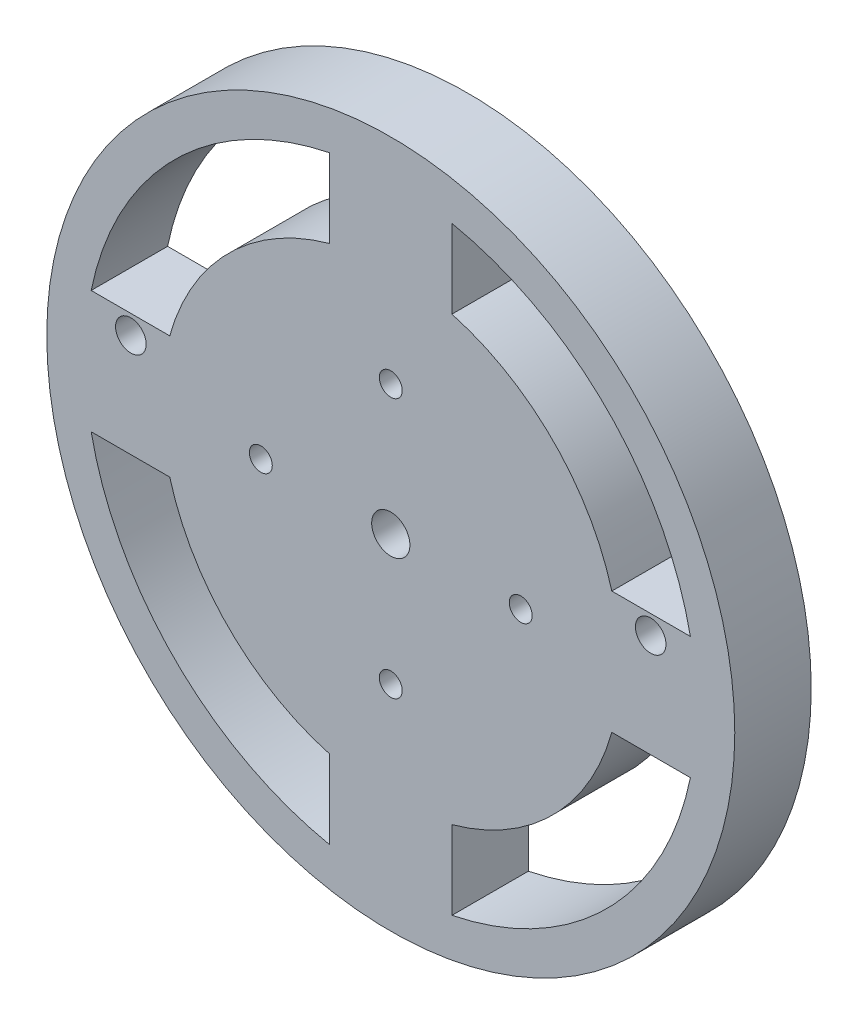
from build123d import *

# Parameters (mm, degrees)
SKETCH1_R           = 45
SKETCH1_R_2         = 2.5
SKETCH1_R_3         = 1.5
BOSS_EXTRUDE1_DEPTH = 10
SKETCH3_R           = 2
CUT_EXTRUDE1_DEPTH  = 10


with BuildPart() as part:
    # Sketch1 → Boss-Extrude1 (new body)
    with BuildSketch(Plane.XY):
        Circle(SKETCH1_R)
        Circle(SKETCH1_R_2, mode=Mode.SUBTRACT)
        with Locations((0, 17)):
            Circle(SKETCH1_R_3, mode=Mode.SUBTRACT)
        with Locations((17, 0)):
            Circle(SKETCH1_R_3, mode=Mode.SUBTRACT)
        with Locations((0, -17)):
            Circle(SKETCH1_R_3, mode=Mode.SUBTRACT)
        with Locations((-17, 0)):
            Circle(SKETCH1_R_3, mode=Mode.SUBTRACT)
        with BuildLine():
            Line((28.91366459, 8), (39.191835885, 8))
            ThreePointArc((39.191835885, 8), (28.284271247, 28.284271247), (8, 39.191835885))
            Line((8, 39.191835885), (8, 28.91366459))
            ThreePointArc((8, 28.91366459), (21.213203436, 21.213203436), (28.91366459, 8))
        make_face(mode=Mode.SUBTRACT)
        with BuildLine():
            Line((28.91366459, -8), (39.191835885, -8))
            ThreePointArc((39.191835885, -8), (28.284271247, -28.284271247), (8, -39.191835885))
            Line((8, -39.191835885), (8, -28.91366459))
            ThreePointArc((8, -28.91366459), (21.213203436, -21.213203436), (28.91366459, -8))
        make_face(mode=Mode.SUBTRACT)
        with BuildLine():
            Line((-8, -28.91366459), (-8, -39.191835885))
            ThreePointArc((-8, -39.191835885), (-28.284271247, -28.284271247), (-39.191835885, -8))
            Line((-39.191835885, -8), (-28.91366459, -8))
            ThreePointArc((-28.91366459, -8), (-21.213203436, -21.213203436), (-8, -28.91366459))
        make_face(mode=Mode.SUBTRACT)
        with BuildLine():
            Line((-39.191835885, 8), (-28.91366459, 8))
            ThreePointArc((-28.91366459, 8), (-21.213203436, 21.213203436), (-8, 28.91366459))
            Line((-8, 28.91366459), (-8, 39.191835885))
            ThreePointArc((-8, 39.191835885), (-28.284271247, 28.284271247), (-39.191835885, 8))
        make_face(mode=Mode.SUBTRACT)
    extrude(amount=BOSS_EXTRUDE1_DEPTH)

    # Sketch3 → Cut-Extrude1 (cut)
    with BuildSketch(Plane.XY.offset(10)):
        with Locations((-34, 5.5)):
            Circle(SKETCH3_R)
        with Locations((34, 5.5)):
            Circle(SKETCH3_R)
    extrude(amount=-CUT_EXTRUDE1_DEPTH, mode=Mode.SUBTRACT)


solid = part.part
